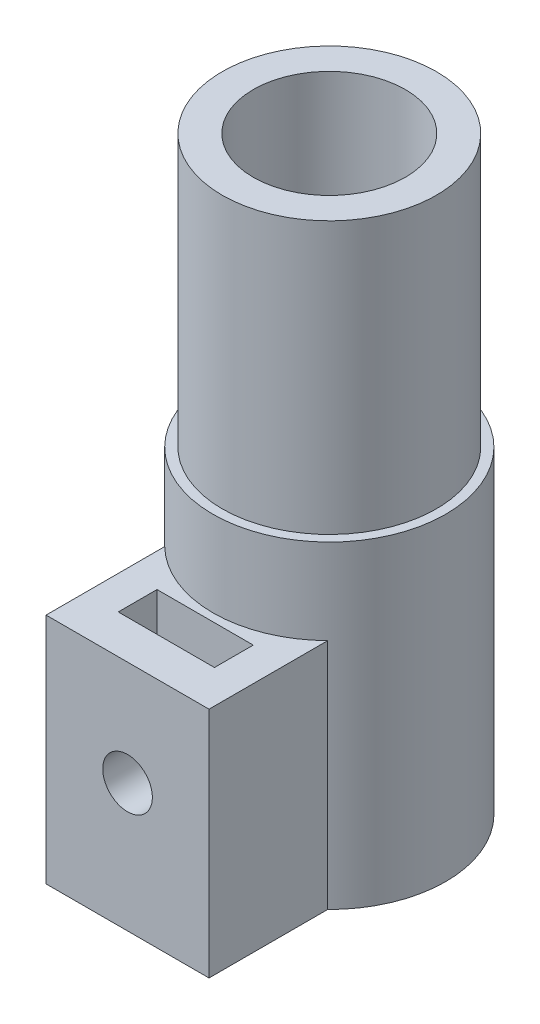
from build123d import *

# Parameters (mm, degrees)
SKETCH1_R                = 6.9
SKETCH1_R_2              = 4.9
BOSS_EXTRUDE1_DEPTH      = 38
SKETCH2_R                = 7.5
SKETCH2_R_2              = 6.9
BOSS_EXTRUDE2_DEPTH      = 20.5
BOSS_EXTRUDE3_REACH      = 22.5
BOSS_EXTRUDE3_END_RADIUS = 7.5
BOSS_EXTRUDE3_START      = 13
SKETCH3_W                = 10.5
SKETCH3_H                = 15
CUT_EXTRUDE1_START       = -2.5
CUT_EXTRUDE1_DEPTH       = 2.5
SKETCH5_R                = 1.6
CUT_EXTRUDE2_DEPTH       = 10


with BuildPart() as part:
    # Sketch1 → Boss-Extrude1 (new body)
    with BuildSketch(Plane(origin=(0, 0, 0), x_dir=(1, 0, 0), z_dir=(0, 1, 0))):
        with Locations(Location((0, 0, 0), (0, 0, 270))):  # turned: the seam where the file's is
            Circle(SKETCH1_R)
        with Locations(Location((0, 0, 0), (0, 0, 270))):  # turned: the seam where the file's is
            Circle(SKETCH1_R_2, mode=Mode.SUBTRACT)
    extrude(amount=-BOSS_EXTRUDE1_DEPTH)

    # Sketch2 → Boss-Extrude2 (add, through all)
    with BuildSketch(Plane(origin=(0, -17.5, 0), x_dir=(-1, 0, 0), z_dir=(0, -1, 0))):
        with Locations(Location((0, 0, 0), (0, 0, 90))):  # turned: the seam where the file's is
            Circle(SKETCH2_R)
        with Locations(Location((0, 0, 0), (0, 0, 270))):  # turned: the seam where the file's is
            Circle(SKETCH2_R_2, mode=Mode.SUBTRACT)
    extrude(amount=BOSS_EXTRUDE2_DEPTH)

    # Boss-Extrude3: up to this cylinder (the profile starts outside it)
    boss_extrude3_end = Plane(origin=(0, -30.5, 0), z_dir=(0, 1, 0)) * Cylinder(BOSS_EXTRUDE3_END_RADIUS, 61, mode=Mode.PRIVATE)
    # Sketch3 → Boss-Extrude3 (add, up to the surface)
    with BuildSketch(Plane.XY.offset(BOSS_EXTRUDE3_START), mode=Mode.PRIVATE) as boss_extrude3_sk1:
        with Locations((0, -30.5)):
            Rectangle(SKETCH3_W, SKETCH3_H)
    boss_extrude3_tool1 = extrude(boss_extrude3_sk1.sketch, amount=-BOSS_EXTRUDE3_REACH, mode=Mode.PRIVATE) - boss_extrude3_end
    add(boss_extrude3_tool1.solids().sort_by_distance((0, -30.5, 13))[0])

    # Sketch4 → Cut-Extrude1 (cut)
    with BuildSketch(Plane.XY.offset(13).offset(CUT_EXTRUDE1_START)):
        with BuildLine():
            Line((-3.1, -23), (-3.1, -29.75))
            ThreePointArc((-3.1, -29.75), (0, -32.85), (3.1, -29.75))
            Line((3.1, -29.75), (3.1, -23))
            Line((3.1, -23), (-3.1, -23))
        make_face()
    extrude(amount=-CUT_EXTRUDE1_DEPTH, mode=Mode.SUBTRACT)

    # Sketch5 → Cut-Extrude2 (cut)
    with BuildSketch(Plane.XY.offset(13)):
        with Locations((0, -29.75)):
            Circle(SKETCH5_R)
    extrude(amount=-CUT_EXTRUDE2_DEPTH, mode=Mode.SUBTRACT)


solid = part.part
